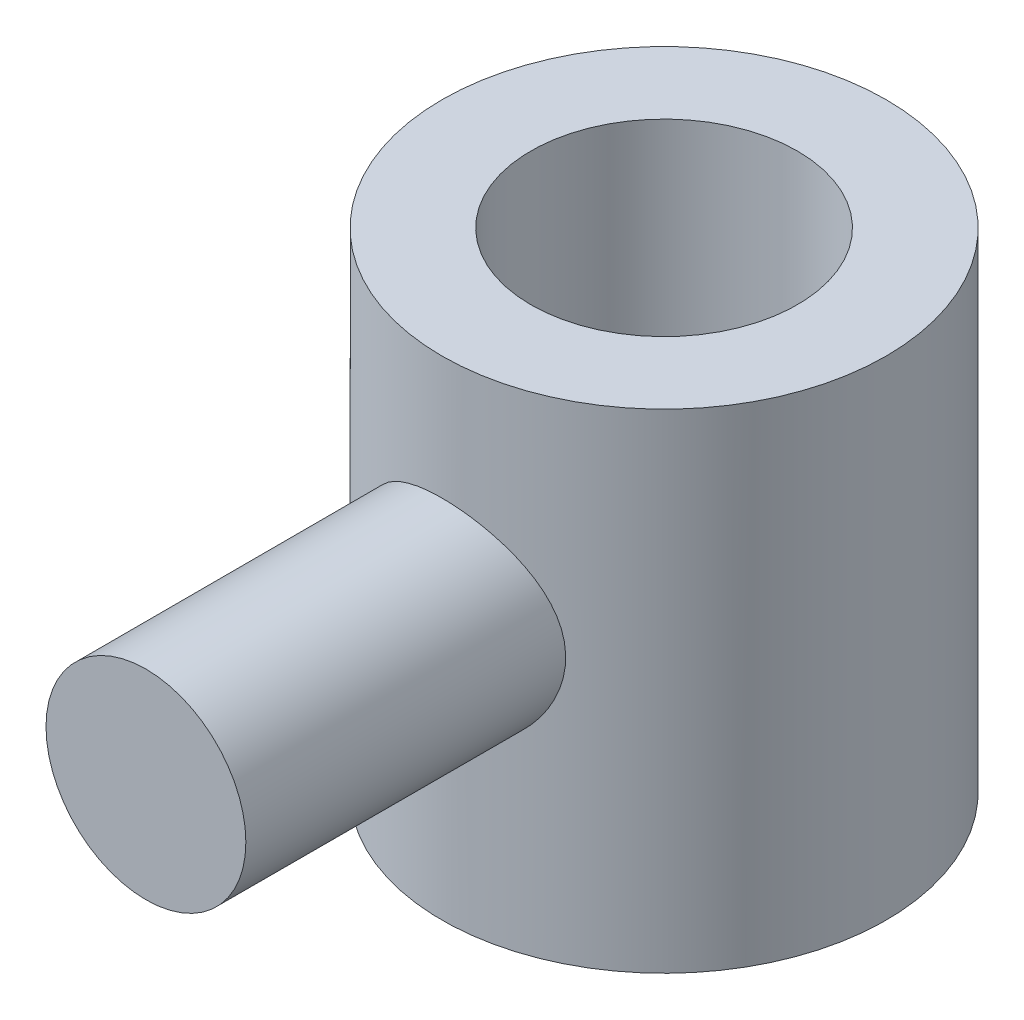
from build123d import *

# Parameters (mm, degrees)
SKETCH1_R           = 150
BOSS_EXTRUDE1_DEPTH = 500
SKETCH2_R           = 150
SKETCH2_R_2         = 90
CUT_EXTRUDE1_DEPTH  = 70
SKETCH4_R           = 67.5
BOSS_EXTRUDE2_DEPTH = 350
SKETCH5_R           = 150
CUT_EXTRUDE3_DEPTH  = 100
SKETCH6_R           = 90
CUT_EXTRUDE4_DEPTH  = 401.0000001


with BuildPart() as part:
    # Sketch1 → Boss-Extrude1 (new body)
    with BuildSketch(Plane(origin=(0, 0, 0), x_dir=(1, 0, 0), z_dir=(0, 1, 0))):
        Circle(SKETCH1_R)
    extrude(amount=BOSS_EXTRUDE1_DEPTH)

    # Sketch2 → Cut-Extrude1 (cut)
    with BuildSketch(Plane.XZ):
        Circle(SKETCH2_R)
        Circle(SKETCH2_R_2, mode=Mode.SUBTRACT)
    extrude(amount=-CUT_EXTRUDE1_DEPTH, mode=Mode.SUBTRACT)

    # Sketch4 → Boss-Extrude2 (add)
    with BuildSketch(Plane.XY):
        with Locations((0, 249.430268714)):
            Circle(SKETCH4_R)
    extrude(amount=BOSS_EXTRUDE2_DEPTH)

    # Sketch5 → Cut-Extrude3 (cut)
    with BuildSketch(Plane(origin=(0, 500, 0), x_dir=(1, 0, 0), z_dir=(0, 1, 0))):
        Circle(SKETCH5_R)
    extrude(amount=-CUT_EXTRUDE3_DEPTH, mode=Mode.SUBTRACT)

    # Sketch6 → Cut-Extrude4 (cut, through all)
    with BuildSketch(Plane.XZ):
        Circle(SKETCH6_R)
    extrude(amount=-CUT_EXTRUDE4_DEPTH, mode=Mode.SUBTRACT)


solid = part.part
